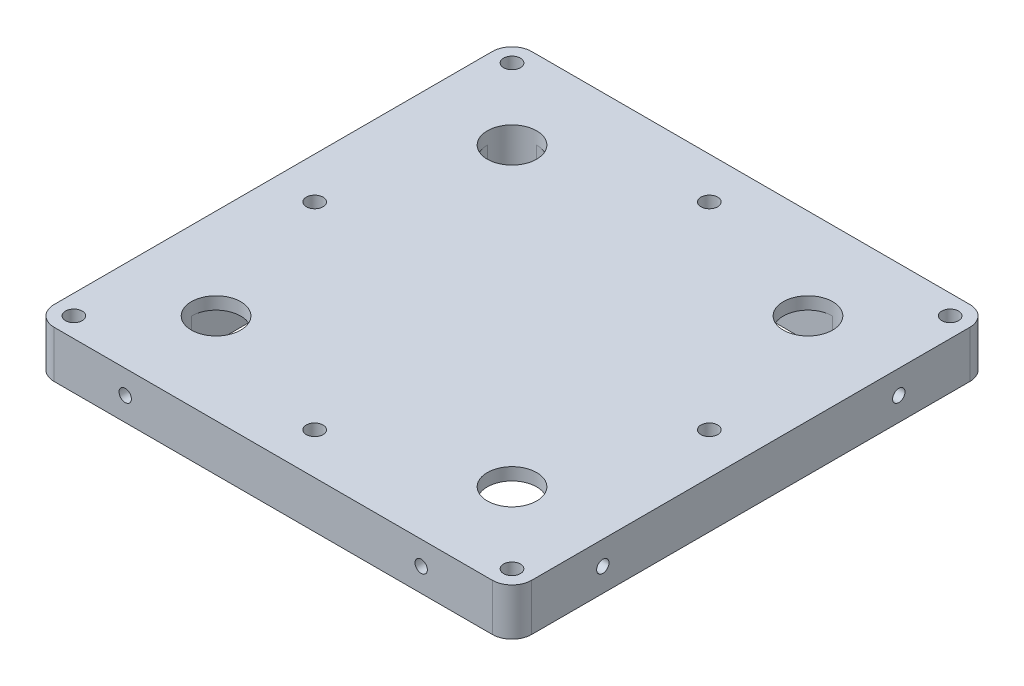
from build123d import *

# Parameters (mm, degrees)
SKETCH1_W                     = 96.825
SKETCH1_H                     = 96.825
BOSS_EXTRUDE1_DEPTH           = 4.7625
FILLET1_R                     = 4
M3X0_5_TAPPED_HOLE1_D         = 2.5
M3X0_5_TAPPED_HOLE1_DEPTH     = 10
M3X0_5_TAPPED_HOLE1_TIP       = 0.751075774
M3X0_5_TAPPED_HOLE2_D         = 2.5
M3X0_5_TAPPED_HOLE2_DEPTH     = 10
M3X0_5_TAPPED_HOLE2_TIP       = 0.751075774
M3_CLEARANCE_HOLE1_D          = 3.4
M3X0_5_TAPPED_HOLE3_D         = 2.5
M3X0_5_TAPPED_HOLE3_DEPTH     = 10
M3X0_5_TAPPED_HOLE3_TIP       = 0.751075774
M3X0_5_TAPPED_HOLE4_D         = 2.5
M3X0_5_TAPPED_HOLE4_DEPTH     = 10
M3X0_5_TAPPED_HOLE4_TIP       = 0.751075774
CSK_FOR_M3_SFHCS1_D           = 3.4
CSK_FOR_M3_SFHCS1_CSINK_D     = 6.72
CSK_FOR_M3_SFHCS1_CSINK_ANGLE = 90
CUT_EXTRUDE1_DEPTH            = 7
SKETCH21_R                    = 5
CUT_EXTRUDE2_DEPTH            = 3.525


with BuildPart() as part:
    # Sketch1 → Boss-Extrude1 (new body, symmetric)
    with BuildSketch(Plane(origin=(0, 0, 0), x_dir=(1, 0, 0), z_dir=(0, 1, 0))):
        Rectangle(SKETCH1_W, SKETCH1_H)
    extrude(amount=BOSS_EXTRUDE1_DEPTH, both=True)

    # Fillet1
    fillet1_edges = [part.edges().sort_by_distance(p)[0] for p in [
        (-48.4125, 0, -48.4125),
        (48.4125, 0, -48.4125),
        (48.4125, 0, 48.4125),
        (-48.4125, 0, 48.4125),
    ]]
    fillet(fillet1_edges, radius=FILLET1_R)

    # M3x0.5 Tapped Hole1
    with Locations(Plane.ZY.offset(48.4125)):
        with Locations((-30, 0), (30, 0)):
            Hole(M3X0_5_TAPPED_HOLE1_D / 2, depth=M3X0_5_TAPPED_HOLE1_DEPTH)
            with Locations((0, 0, -(M3X0_5_TAPPED_HOLE1_DEPTH + M3X0_5_TAPPED_HOLE1_TIP / 2))):  # 118° drill point
                Cone(0, M3X0_5_TAPPED_HOLE1_D / 2, M3X0_5_TAPPED_HOLE1_TIP, mode=Mode.SUBTRACT)

    # M3x0.5 Tapped Hole2
    with Locations(Plane(origin=(0, 0, -48.4125), x_dir=(-1, 0, 0), z_dir=(0, 0, -1))):
        with Locations((-30, 0), (30, 0)):
            Hole(M3X0_5_TAPPED_HOLE2_D / 2, depth=M3X0_5_TAPPED_HOLE2_DEPTH)
            with Locations((0, 0, -(M3X0_5_TAPPED_HOLE2_DEPTH + M3X0_5_TAPPED_HOLE2_TIP / 2))):  # 118° drill point
                Cone(0, M3X0_5_TAPPED_HOLE2_D / 2, M3X0_5_TAPPED_HOLE2_TIP, mode=Mode.SUBTRACT)

    # M3 Clearance Hole1 (through all)
    with Locations(Plane(origin=(0, 4.7625, 0), x_dir=(1, 0, 0), z_dir=(0, 1, 0))):
        with Locations((-44.4125, 44.4125), (44.4125, 44.4125), (44.4125, -44.4125), (-44.4125, -44.4125)):
            Hole(M3_CLEARANCE_HOLE1_D / 2)

    # M3x0.5 Tapped Hole3
    with Locations(Plane(origin=(48.4125, 0, 0), x_dir=(0, 0, -1), z_dir=(1, 0, 0))):
        with Locations((-30, 0), (30, 0)):
            Hole(M3X0_5_TAPPED_HOLE3_D / 2, depth=M3X0_5_TAPPED_HOLE3_DEPTH)
            with Locations((0, 0, -(M3X0_5_TAPPED_HOLE3_DEPTH + M3X0_5_TAPPED_HOLE3_TIP / 2))):  # 118° drill point
                Cone(0, M3X0_5_TAPPED_HOLE3_D / 2, M3X0_5_TAPPED_HOLE3_TIP, mode=Mode.SUBTRACT)

    # M3x0.5 Tapped Hole4
    with Locations(Plane.XY.offset(48.4125)):
        with Locations((-30, 0), (30, 0)):
            Hole(M3X0_5_TAPPED_HOLE4_D / 2, depth=M3X0_5_TAPPED_HOLE4_DEPTH)
            with Locations((0, 0, -(M3X0_5_TAPPED_HOLE4_DEPTH + M3X0_5_TAPPED_HOLE4_TIP / 2))):  # 118° drill point
                Cone(0, M3X0_5_TAPPED_HOLE4_D / 2, M3X0_5_TAPPED_HOLE4_TIP, mode=Mode.SUBTRACT)

    # CSK for M3 SFHCS1 (through all)
    with Locations(Plane(origin=(0, -4.7625, 0), x_dir=(-1, 0, 0), z_dir=(0, -1, 0))):
        with Locations((-40, 0), (0, 40), (40, 0), (0, -40)):
            CounterSinkHole(CSK_FOR_M3_SFHCS1_D / 2, CSK_FOR_M3_SFHCS1_CSINK_D / 2, counter_sink_angle=CSK_FOR_M3_SFHCS1_CSINK_ANGLE)

    # Sketch20 → Cut-Extrude1 (cut)
    with BuildSketch(Plane.XZ.offset(4.7625)):
        with BuildLine():
            Line((30, -35), (-30, -35))
            ThreePointArc((-30, -35), (-33.535533906, -33.535533906), (-35, -30))
            Line((-35, -30), (-35, 30))
            ThreePointArc((-35, 30), (-33.535533906, 33.535533906), (-30, 35))
            Line((-30, 35), (30, 35))
            ThreePointArc((30, 35), (33.535533906, 33.535533906), (35, 30))
            Line((35, 30), (35, -30))
            ThreePointArc((35, -30), (33.535533906, -33.535533906), (30, -35))
        make_face()
    extrude(amount=-CUT_EXTRUDE1_DEPTH, mode=Mode.SUBTRACT)

    # Sketch21 → Cut-Extrude2 (cut, through all)
    with BuildSketch(Plane.XZ.offset(-2.2375)):
        with Locations((-30, 30)):
            Circle(SKETCH21_R)
        with Locations((30, 30)):
            Circle(SKETCH21_R)
        with Locations((30, -30)):
            Circle(SKETCH21_R)
        with Locations((-30, -30)):
            Circle(SKETCH21_R)
    extrude(amount=-CUT_EXTRUDE2_DEPTH, mode=Mode.SUBTRACT)


solid = part.part
